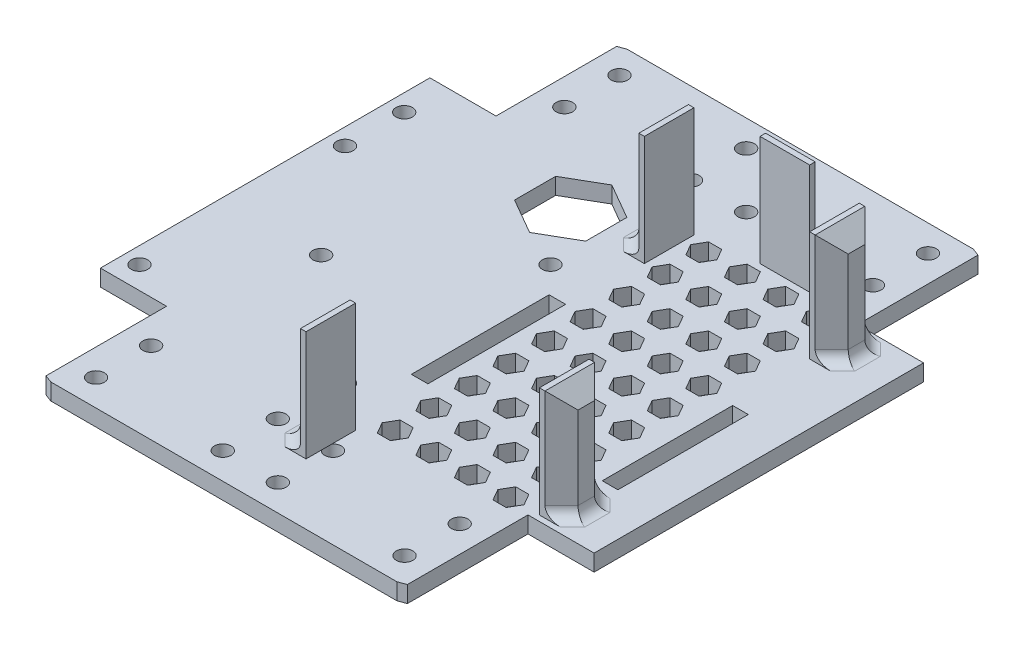
from build123d import *

# Parameters (mm, degrees)
SKETCH1_R           = 1.5
BOSS_EXTRUDE1_DEPTH = 3
SKETCH2_R           = 1.5
CUT_EXTRUDE1_DEPTH  = 10
CUT_EXTRUDE2_DEPTH  = 10
SKETCH4_W           = 4
SKETCH4_H           = 9
SKETCH4_W_2         = 9
SKETCH4_H_2         = 4
BOSS_EXTRUDE2_DEPTH = 20
CUT_EXTRUDE3_DEPTH  = 5
CHAMFER1_SIZE       = 3
CHAMFER2_SIZE       = 3
FILLET1_R           = 2
SKETCH6_W           = 2.840333347
SKETCH6_H           = 23.669444554
SKETCH6_W_2         = 3
SKETCH6_H_2         = 25
CUT_EXTRUDE4_DEPTH  = 5
SKETCH7_R           = 1.5
CUT_EXTRUDE5_DEPTH  = 10


with BuildPart() as part:
    # Sketch1 → Boss-Extrude1 (new body)
    with BuildSketch(Plane(origin=(0, 0, 0), x_dir=(1, 0, 0), z_dir=(0, 1, 0))):
        Polygon((-32.8, -43.179234876), (-32.8, -21.3), (-44.8, -21.3), (-44.8, 38.5), (-32.8, 38.5), (-32.8, 60.379234876), (-31.414895547, 60.9), (31.414895547, 60.9), (32.8, 60.379234876), (32.8, 38.5), (44.8, 38.5), (44.8, -21.3), (32.8, -21.3), (32.8, -43.179234876), (31.414895547, -43.7), (-31.414895547, -43.7), align=None)
        with Locations((-28, -28.9)):
            Circle(SKETCH1_R, mode=Mode.SUBTRACT)
        with Locations((-28, -38.9)):
            Circle(SKETCH1_R, mode=Mode.SUBTRACT)
        with Locations((-5, -28.9)):
            Circle(SKETCH1_R, mode=Mode.SUBTRACT)
        with Locations((5, -28.9)):
            Circle(SKETCH1_R, mode=Mode.SUBTRACT)
        with Locations((-5, -38.9)):
            Circle(SKETCH1_R, mode=Mode.SUBTRACT)
        with Locations((5, -38.9)):
            Circle(SKETCH1_R, mode=Mode.SUBTRACT)
        with Locations((28, -28.9)):
            Circle(SKETCH1_R, mode=Mode.SUBTRACT)
        with Locations((28, -38.9)):
            Circle(SKETCH1_R, mode=Mode.SUBTRACT)
        with Locations((28, 56.1)):
            Circle(SKETCH1_R, mode=Mode.SUBTRACT)
        with Locations((28, 46.1)):
            Circle(SKETCH1_R, mode=Mode.SUBTRACT)
        with Locations((5, 56.1)):
            Circle(SKETCH1_R, mode=Mode.SUBTRACT)
        with Locations((-5, 56.1)):
            Circle(SKETCH1_R, mode=Mode.SUBTRACT)
        with Locations((5, 46.1)):
            Circle(SKETCH1_R, mode=Mode.SUBTRACT)
        with Locations((-5, 46.1)):
            Circle(SKETCH1_R, mode=Mode.SUBTRACT)
        with Locations((-28, 56.1)):
            Circle(SKETCH1_R, mode=Mode.SUBTRACT)
        with Locations((-28, 46.1)):
            Circle(SKETCH1_R, mode=Mode.SUBTRACT)
    extrude(amount=BOSS_EXTRUDE1_DEPTH)

    # Sketch2 → Cut-Extrude1 (cut)
    with BuildSketch(Plane(origin=(0, 3, 0), x_dir=(1, 0, 0), z_dir=(0, 1, 0))):
        with Locations((-41.8, -17.21158168)):
            Circle(SKETCH2_R)
        with Locations((-4.5, -17.21158168)):
            Circle(SKETCH2_R)
        with Locations((-41.8, 20.08841832)):
            Circle(SKETCH2_R)
        with Locations((-4.5, 20.08841832)):
            Circle(SKETCH2_R)
    extrude(amount=-CUT_EXTRUDE1_DEPTH, mode=Mode.SUBTRACT)

    # Sketch3 → Cut-Extrude2 (cut)
    with BuildSketch(Plane(origin=(0, 3, 0), x_dir=(1, 0, 0), z_dir=(0, 1, 0))):
        Polygon((-11.450000453, 23.247301403), (-4.989450941, 26.977301403), (-4.989450941, 34.437301403), (-11.450000453, 38.167301403), (-17.910549965, 34.437301403), (-17.910549965, 26.977301403), align=None)
    extrude(amount=-CUT_EXTRUDE2_DEPTH, mode=Mode.SUBTRACT)

    # Sketch4 → Boss-Extrude2 (add)
    with BuildSketch(Plane(origin=(0, 3, 0), x_dir=(1, 0, 0), z_dir=(0, 1, 0))):
        with Locations((35.863330882, 33.262395166)):
            Rectangle(SKETCH4_W, SKETCH4_H)
        with Locations((1.863330882, 33.262395166)):
            Rectangle(SKETCH4_W, SKETCH4_H)
        with Locations((18.863330882, 41.262395166)):
            Rectangle(SKETCH4_W_2, SKETCH4_H_2)
        with Locations((35.863330882, -15.775744579)):
            Rectangle(SKETCH4_W, SKETCH4_H)
        with Locations((1.863330882, -28.150126082)):
            Rectangle(SKETCH4_W, SKETCH4_H)
    extrude(amount=BOSS_EXTRUDE2_DEPTH)

    # Sketch5 → Cut-Extrude3 (cut)
    with BuildSketch(Plane(origin=(0, 3, 0), x_dir=(1, 0, 0), z_dir=(0, 1, 0))):
        Polygon((6.271449024, 33.878428807), (8.655784408, 33.878428807), (9.8479521, 35.943323821), (8.655784408, 38.008218834), (6.271449024, 38.008218834), (5.079281332, 35.943323821), align=None)
        Polygon((13.271449024, 33.878428807), (15.655784408, 33.878428807), (16.8479521, 35.943323821), (15.655784408, 38.008218834), (13.271449024, 38.008218834), (12.079281332, 35.943323821), align=None)
        Polygon((20.271449024, 33.878428807), (22.655784408, 33.878428807), (23.8479521, 35.943323821), (22.655784408, 38.008218834), (20.271449024, 38.008218834), (19.079281332, 35.943323821), align=None)
        Polygon((27.271449024, 33.878428807), (29.655784408, 33.878428807), (30.8479521, 35.943323821), (29.655784408, 38.008218834), (27.271449024, 38.008218834), (26.079281332, 35.943323821), align=None)
        Polygon((13.271449024, 26.878428807), (15.655784408, 26.878428807), (16.8479521, 28.943323821), (15.655784408, 31.008218834), (13.271449024, 31.008218834), (12.079281332, 28.943323821), align=None)
        Polygon((20.271449024, 26.878428807), (22.655784408, 26.878428807), (23.8479521, 28.943323821), (22.655784408, 31.008218834), (20.271449024, 31.008218834), (19.079281332, 28.943323821), align=None)
        Polygon((27.271449024, 26.878428807), (29.655784408, 26.878428807), (30.8479521, 28.943323821), (29.655784408, 31.008218834), (27.271449024, 31.008218834), (26.079281332, 28.943323821), align=None)
        Polygon((13.271449024, 19.878428807), (15.655784408, 19.878428807), (16.8479521, 21.943323821), (15.655784408, 24.008218834), (13.271449024, 24.008218834), (12.079281332, 21.943323821), align=None)
        Polygon((20.271449024, 19.878428807), (22.655784408, 19.878428807), (23.8479521, 21.943323821), (22.655784408, 24.008218834), (20.271449024, 24.008218834), (19.079281332, 21.943323821), align=None)
        Polygon((27.271449024, 19.878428807), (29.655784408, 19.878428807), (30.8479521, 21.943323821), (29.655784408, 24.008218834), (27.271449024, 24.008218834), (26.079281332, 21.943323821), align=None)
        Polygon((13.271449024, 12.878428807), (15.655784408, 12.878428807), (16.8479521, 14.943323821), (15.655784408, 17.008218834), (13.271449024, 17.008218834), (12.079281332, 14.943323821), align=None)
        Polygon((20.271449024, 12.878428807), (22.655784408, 12.878428807), (23.8479521, 14.943323821), (22.655784408, 17.008218834), (20.271449024, 17.008218834), (19.079281332, 14.943323821), align=None)
        Polygon((27.271449024, 12.878428807), (29.655784408, 12.878428807), (30.8479521, 14.943323821), (29.655784408, 17.008218834), (27.271449024, 17.008218834), (26.079281332, 14.943323821), align=None)
        Polygon((13.271449024, 5.878428807), (15.655784408, 5.878428807), (16.8479521, 7.943323821), (15.655784408, 10.008218834), (13.271449024, 10.008218834), (12.079281332, 7.943323821), align=None)
        Polygon((20.271449024, 5.878428807), (22.655784408, 5.878428807), (23.8479521, 7.943323821), (22.655784408, 10.008218834), (20.271449024, 10.008218834), (19.079281332, 7.943323821), align=None)
        Polygon((27.271449024, 5.878428807), (29.655784408, 5.878428807), (30.8479521, 7.943323821), (29.655784408, 10.008218834), (27.271449024, 10.008218834), (26.079281332, 7.943323821), align=None)
        Polygon((13.271449024, -1.121571193), (15.655784408, -1.121571193), (16.8479521, 0.943323821), (15.655784408, 3.008218834), (13.271449024, 3.008218834), (12.079281332, 0.943323821), align=None)
        Polygon((20.271449024, -1.121571193), (22.655784408, -1.121571193), (23.8479521, 0.943323821), (22.655784408, 3.008218834), (20.271449024, 3.008218834), (19.079281332, 0.943323821), align=None)
        Polygon((27.271449024, -1.121571193), (29.655784408, -1.121571193), (30.8479521, 0.943323821), (29.655784408, 3.008218834), (27.271449024, 3.008218834), (26.079281332, 0.943323821), align=None)
        Polygon((13.271449024, -8.121571193), (15.655784408, -8.121571193), (16.8479521, -6.056676179), (15.655784408, -3.991781166), (13.271449024, -3.991781166), (12.079281332, -6.056676179), align=None)
        Polygon((20.271449024, -8.121571193), (22.655784408, -8.121571193), (23.8479521, -6.056676179), (22.655784408, -3.991781166), (20.271449024, -3.991781166), (19.079281332, -6.056676179), align=None)
        Polygon((27.271449024, -8.121571193), (29.655784408, -8.121571193), (30.8479521, -6.056676179), (29.655784408, -3.991781166), (27.271449024, -3.991781166), (26.079281332, -6.056676179), align=None)
        Polygon((13.271449024, -15.121571193), (15.655784408, -15.121571193), (16.8479521, -13.056676179), (15.655784408, -10.991781166), (13.271449024, -10.991781166), (12.079281332, -13.056676179), align=None)
        Polygon((20.271449024, -15.121571193), (22.655784408, -15.121571193), (23.8479521, -13.056676179), (22.655784408, -10.991781166), (20.271449024, -10.991781166), (19.079281332, -13.056676179), align=None)
        Polygon((27.271449024, -15.121571193), (29.655784408, -15.121571193), (30.8479521, -13.056676179), (29.655784408, -10.991781166), (27.271449024, -10.991781166), (26.079281332, -13.056676179), align=None)
        Polygon((13.271449024, -22.121571193), (15.655784408, -22.121571193), (16.8479521, -20.056676179), (15.655784408, -17.991781166), (13.271449024, -17.991781166), (12.079281332, -20.056676179), align=None)
        Polygon((20.271449024, -22.121571193), (22.655784408, -22.121571193), (23.8479521, -20.056676179), (22.655784408, -17.991781166), (20.271449024, -17.991781166), (19.079281332, -20.056676179), align=None)
        Polygon((27.271449024, -22.121571193), (29.655784408, -22.121571193), (30.8479521, -20.056676179), (29.655784408, -17.991781166), (27.271449024, -17.991781166), (26.079281332, -20.056676179), align=None)
        Polygon((6.271449024, 26.878428807), (8.655784408, 26.878428807), (9.8479521, 28.943323821), (8.655784408, 31.008218834), (6.271449024, 31.008218834), (5.079281332, 28.943323821), align=None)
        Polygon((6.271449024, 19.878428807), (8.655784408, 19.878428807), (9.8479521, 21.943323821), (8.655784408, 24.008218834), (6.271449024, 24.008218834), (5.079281332, 21.943323821), align=None)
        Polygon((6.271449024, 12.878428807), (8.655784408, 12.878428807), (9.8479521, 14.943323821), (8.655784408, 17.008218834), (6.271449024, 17.008218834), (5.079281332, 14.943323821), align=None)
        Polygon((6.271449024, 5.878428807), (8.655784408, 5.878428807), (9.8479521, 7.943323821), (8.655784408, 10.008218834), (6.271449024, 10.008218834), (5.079281332, 7.943323821), align=None)
        Polygon((6.271449024, -1.121571193), (8.655784408, -1.121571193), (9.8479521, 0.943323821), (8.655784408, 3.008218834), (6.271449024, 3.008218834), (5.079281332, 0.943323821), align=None)
        Polygon((6.271449024, -8.121571193), (8.655784408, -8.121571193), (9.8479521, -6.056676179), (8.655784408, -3.991781166), (6.271449024, -3.991781166), (5.079281332, -6.056676179), align=None)
        Polygon((6.271449024, -15.121571193), (8.655784408, -15.121571193), (9.8479521, -13.056676179), (8.655784408, -10.991781166), (6.271449024, -10.991781166), (5.079281332, -13.056676179), align=None)
        Polygon((6.271449024, -22.121571193), (8.655784408, -22.121571193), (9.8479521, -20.056676179), (8.655784408, -17.991781166), (6.271449024, -17.991781166), (5.079281332, -20.056676179), align=None)
    extrude(amount=-CUT_EXTRUDE3_DEPTH, mode=Mode.SUBTRACT)

    # Chamfer1
    chamfer1_edges = [part.edges().sort_by_distance(p)[0] for p in [
        (37.863330882, 23, -33.262395166),
        (-0.136669118, 23, -33.262395166),
        (18.863330882, 23, -43.262395166),
        (37.863330882, 23, 15.775744579),
        (-0.136669118, 23, 28.150126082),
    ]]
    chamfer(chamfer1_edges, length=CHAMFER1_SIZE)

    # Chamfer2
    chamfer2_edges = [part.edges().sort_by_distance(p)[0] for p in [
        (-0.136669118, 11.5, 32.650126082),
        (-0.136669118, 11.5, 23.650126082),
        (37.863330882, 11.5, 11.275744579),
        (37.863330882, 11.5, 20.275744579),
        (37.863330882, 11.5, -28.762395166),
        (37.863330882, 11.5, -37.762395166),
        (23.363330882, 11.5, -43.262395166),
        (14.363330882, 11.5, -43.262395166),
        (-0.136669118, 11.5, -37.762395166),
        (-0.136669118, 11.5, -28.762395166),
    ]]
    chamfer(chamfer2_edges, length=CHAMFER2_SIZE)

    # Fillet1
    fillet1_edges = [part.edges().sort_by_distance(p)[0] for p in [
        (-0.136669118, 3, 28.150126082),
        (37.863330882, 3, 15.775744579),
        (37.863330882, 3, -33.262395166),
        (18.863330882, 3, -43.262395166),
        (-0.136669118, 3, -33.262395166),
        (1.363330882, 3, 31.150126082),
        (1.363330882, 3, 25.150126082),
        (36.363330882, 3, 12.775744579),
        (36.363330882, 3, 18.775744579),
        (36.363330882, 3, -30.262395166),
        (36.363330882, 3, -36.262395166),
        (21.863330882, 3, -41.762395166),
        (15.863330882, 3, -41.762395166),
        (1.363330882, 3, -36.262395166),
        (1.363330882, 3, -30.262395166),
    ]]
    fillet(fillet1_edges, radius=FILLET1_R)

    # Sketch6 → Cut-Extrude4 (cut)
    with BuildSketch(Plane(origin=(0, 3, 0), x_dir=(1, 0, 0), z_dir=(0, 1, 0))):
        with Locations((35.595984898, 2.638077543)):
            Rectangle(SKETCH6_W, SKETCH6_H)
        with Locations((1.617683293, 2.716549371)):
            Rectangle(SKETCH6_W_2, SKETCH6_H_2)
    extrude(amount=-CUT_EXTRUDE4_DEPTH, mode=Mode.SUBTRACT)

    # Sketch7 → Cut-Extrude5 (cut)
    with BuildSketch(Plane(origin=(0, 0, 0), x_dir=(-1, 0, 0), z_dir=(0, -1, 0))):
        with Locations((26.805736655, 0.765019833)):
            Circle(SKETCH7_R)
        with Locations((41.725736655, 30.755019833)):
            Circle(SKETCH7_R)
    extrude(amount=-CUT_EXTRUDE5_DEPTH, mode=Mode.SUBTRACT)


solid = part.part
